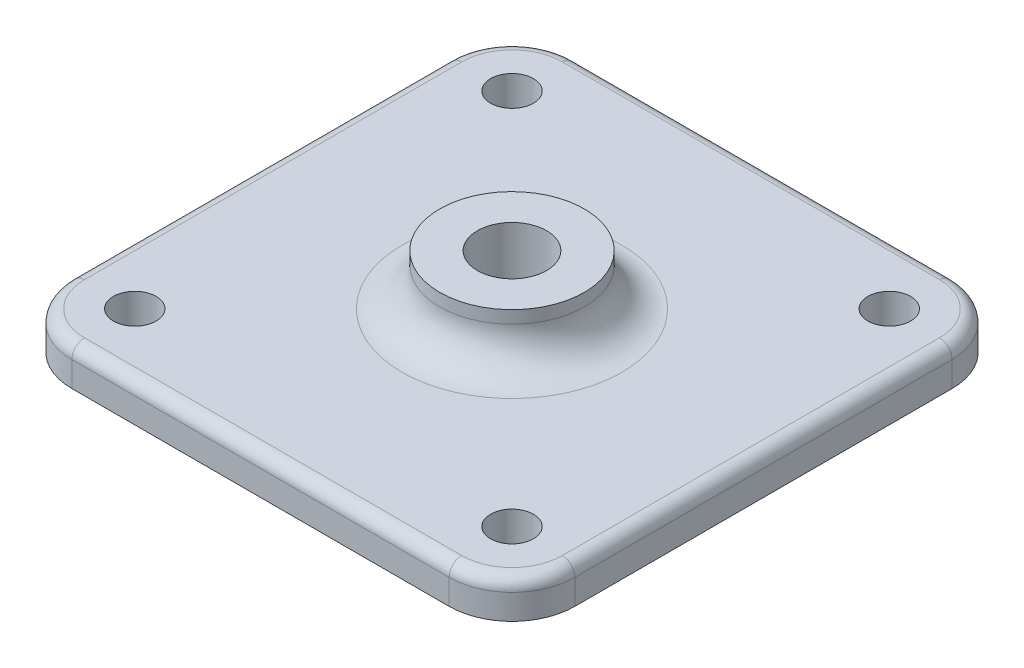
from build123d import *

# Parameters (mm, degrees)
SKETCH1_R           = 5.75
SKETCH1_R_2         = 2.75
BOSS_EXTRUDE1_DEPTH = 4
BOSS_EXTRUDE2_START = -3
SKETCH1_3_R         = 1.7
SKETCH1_3_R_2       = 2.75
BOSS_EXTRUDE2_DEPTH = 3
FILLET1_R           = 3
FILLET2_R           = 1


with BuildPart() as part:
    # Sketch1 → Boss-Extrude1 (new body)
    with BuildSketch(Plane(origin=(0, 0, 0), x_dir=(1, 0, 0), z_dir=(0, 1, 0))):
        Circle(SKETCH1_R)
        Circle(SKETCH1_R_2, mode=Mode.SUBTRACT)
    extrude(amount=BOSS_EXTRUDE1_DEPTH)

    # Sketch1_3 → Boss-Extrude2 (add)
    with BuildSketch(Plane(origin=(0, 0, 0), x_dir=(1, 0, 0), z_dir=(0, 1, 0)).offset(BOSS_EXTRUDE2_START)):
        with BuildLine():
            ThreePointArc((-20, -15), (-18.535533906, -18.535533906), (-15, -20))
            Line((-15, -20), (15, -20))
            ThreePointArc((15, -20), (18.535533906, -18.535533906), (20, -15))
            Line((20, -15), (20, 15))
            ThreePointArc((20, 15), (18.535533906, 18.535533906), (15, 20))
            Line((15, 20), (-15, 20))
            ThreePointArc((-15, 20), (-18.535533906, 18.535533906), (-20, 15))
            Line((-20, 15), (-20, -15))
        make_face()
        with Locations((-15, -15)):
            Circle(SKETCH1_3_R, mode=Mode.SUBTRACT)
        with Locations((15, -15)):
            Circle(SKETCH1_3_R, mode=Mode.SUBTRACT)
        with Locations((-15, 15)):
            Circle(SKETCH1_3_R, mode=Mode.SUBTRACT)
        with Locations((15, 15)):
            Circle(SKETCH1_3_R, mode=Mode.SUBTRACT)
        Circle(SKETCH1_3_R_2, mode=Mode.SUBTRACT)
    extrude(amount=BOSS_EXTRUDE2_DEPTH)

    # Fillet1
    fillet1_edges = [part.edges().sort_by_distance(p)[0] for p in [
        (-5.75, 0, 0),
    ]]
    fillet(fillet1_edges, radius=FILLET1_R)

    # Fillet2
    fillet2_edges = [part.edges().sort_by_distance(p)[0] for p in [
        (-18.535533906, 0, -18.535533906),
        (-20, 0, 0),
        (-18.535533906, 0, 18.535533906),
        (0, 0, 20),
        (18.535533906, 0, 18.535533906),
        (20, 0, 0),
        (18.535533906, 0, -18.535533906),
        (0, 0, -20),
    ]]
    fillet(fillet2_edges, radius=FILLET2_R)


solid = part.part
